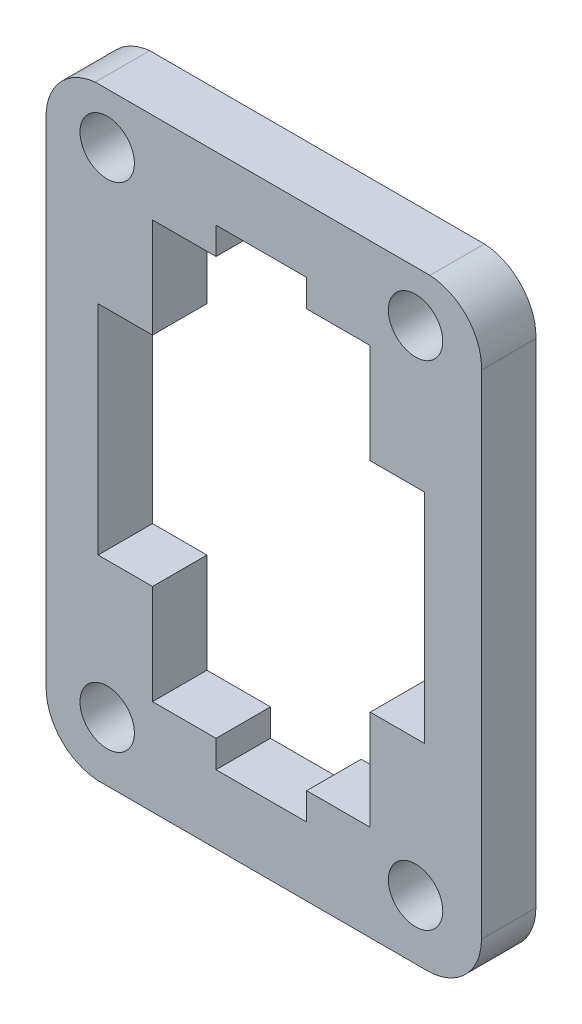
from build123d import *

# Parameters (mm, degrees)
MODEL_R             = 1.500000008
MODEL_R_2           = 1.499950004
MODEL_R_3           = 1.500050014
MODEL_R_4           = 1.500000002
BOSS_EXTRUDE1_DEPTH = 3


with BuildPart() as part:
    # Model → Boss-Extrude1 (new body)
    with BuildSketch(Plane.XY):
        with BuildLine():
            Line((41.133407433, 54.383216824), (41.133407433, 44.212078484))
            Line((41.133407433, 44.212078484), (41.133407433, 27.226016824))
            add(Edge.make_bspline(
                [(41.133407433, 27.226016824), (41.133407433, 26.430416824), (41.449407433, 25.667416824), (42.012007433, 25.104816824)],
                knots=[0, 0, 0, 0, 0.333333333, 0.333333333, 0.333333333, 0.333333333], degree=3))
            add(Edge.make_bspline(
                [(42.012007433, 25.104816824), (42.574607433, 24.542216824), (43.337707433, 24.226016824), (44.133407433, 24.226016824)],
                knots=[0.333333333, 0.333333333, 0.333333333, 0.333333333, 1, 1, 1, 1], degree=3))
            Line((44.133407433, 24.226016824), (62.133207433, 24.226016824))
            ThreePointArc((62.133207433, 24.226016824), (64.254457434, 25.104766823), (65.133207433, 27.226016824))
            Line((65.133207433, 27.226016824), (65.133207433, 44.226016824))
            Line((65.133207433, 44.226016824), (65.133207433, 54.397160398))
            ThreePointArc((65.133207433, 54.397160398), (64.34779637, 56.530036555), (62.292266716, 57.5))
            Line((62.292266716, 57.5), (59.346369656, 57.5))
            Line((59.346369656, 57.5), (47.346484736, 57.5))
            Line((47.346484736, 57.5), (43.843018497, 57.5))
            ThreePointArc((43.843018497, 57.5), (41.866482804, 56.482116631), (41.133407433, 54.383216824))
        make_face()
        with Locations((44.499899992, 27.500000005)):
            Circle(MODEL_R, mode=Mode.SUBTRACT)
        with Locations((61.499949997, 27.500049997)):
            Circle(MODEL_R_2, mode=Mode.SUBTRACT)
        Polygon((50.4999, 52.5), (50.4999, 54), (55.4999, 54), (55.4999, 52.5), (58.9999, 52.5), (58.9999, 47), (61.9999, 47), (61.9999, 35), (58.9999, 35), (58.9999, 29.5), (55.4999, 29.5), (55.4999, 28.0001), (50.4999, 28.0001), (50.4999, 29.5), (46.9999, 29.5), (46.9999, 35), (44.0001, 35), (44.0001, 47), (46.9999, 47), (46.9999, 52.5), align=None, mode=Mode.SUBTRACT)
        with Locations((44.499849987, 54.700050007)):
            Circle(MODEL_R_3, mode=Mode.SUBTRACT)
        with Locations((61.499900002, 54.700099998)):
            Circle(MODEL_R_4, mode=Mode.SUBTRACT)
    extrude(amount=BOSS_EXTRUDE1_DEPTH)


solid = part.part
